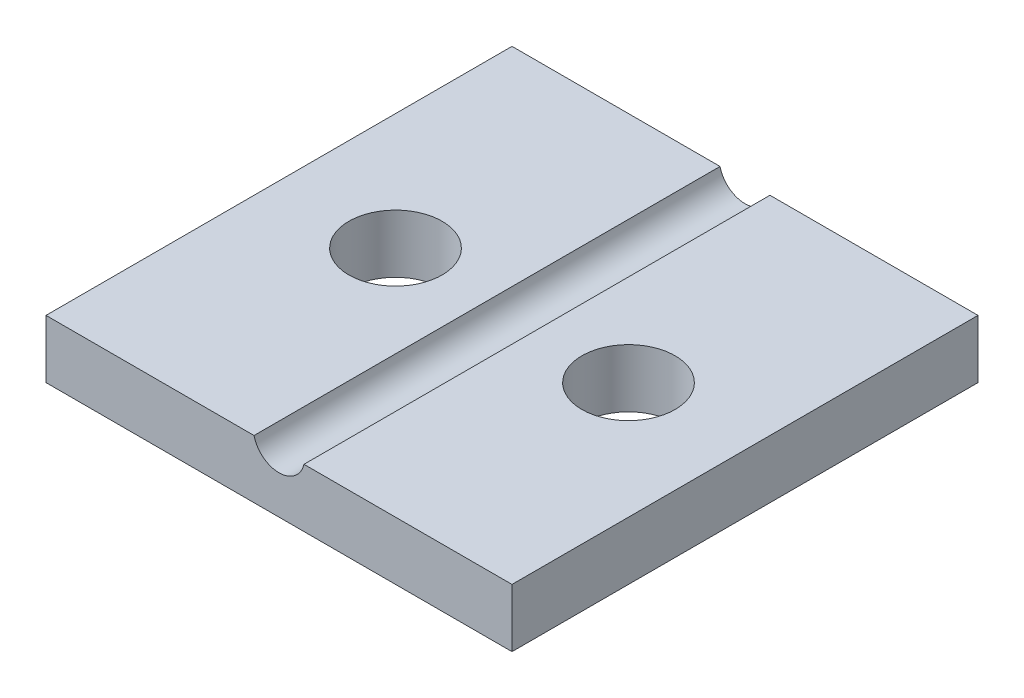
from build123d import *

# Parameters (mm, degrees)
SKETCH1_W           = 20
SKETCH1_H           = 20
BOSS_EXTRUDE1_DEPTH = 2.5
SKETCH2_R           = 1.1
CUT_EXTRUDE1_DEPTH  = 21
SKETCH3_R           = 2
CUT_EXTRUDE2_DEPTH  = 3.5


with BuildPart() as part:
    # Sketch1 → Boss-Extrude1 (new body)
    with BuildSketch(Plane(origin=(0, 0, 0), x_dir=(1, 0, 0), z_dir=(0, 1, 0))):
        with Locations((-50.754716981, 42.075471698)):
            Rectangle(SKETCH1_W, SKETCH1_H)
    extrude(amount=BOSS_EXTRUDE1_DEPTH)

    # Sketch2 → Cut-Extrude1 (cut, through all)
    with BuildSketch(Plane.XY.offset(-32.075471698)):
        with Locations((-50.754716981, 2.75)):
            Circle(SKETCH2_R)
    extrude(amount=-CUT_EXTRUDE1_DEPTH, mode=Mode.SUBTRACT)

    # Sketch3 → Cut-Extrude2 (cut, through all)
    with BuildSketch(Plane(origin=(0, 2.5, 0), x_dir=(1, 0, 0), z_dir=(0, 1, 0))):
        with Locations((-55.754716981, 42.075471698)):
            Circle(SKETCH3_R)
        with Locations((-45.754716981, 42.075471698)):
            Circle(SKETCH3_R)
    extrude(amount=-CUT_EXTRUDE2_DEPTH, mode=Mode.SUBTRACT)


solid = part.part
